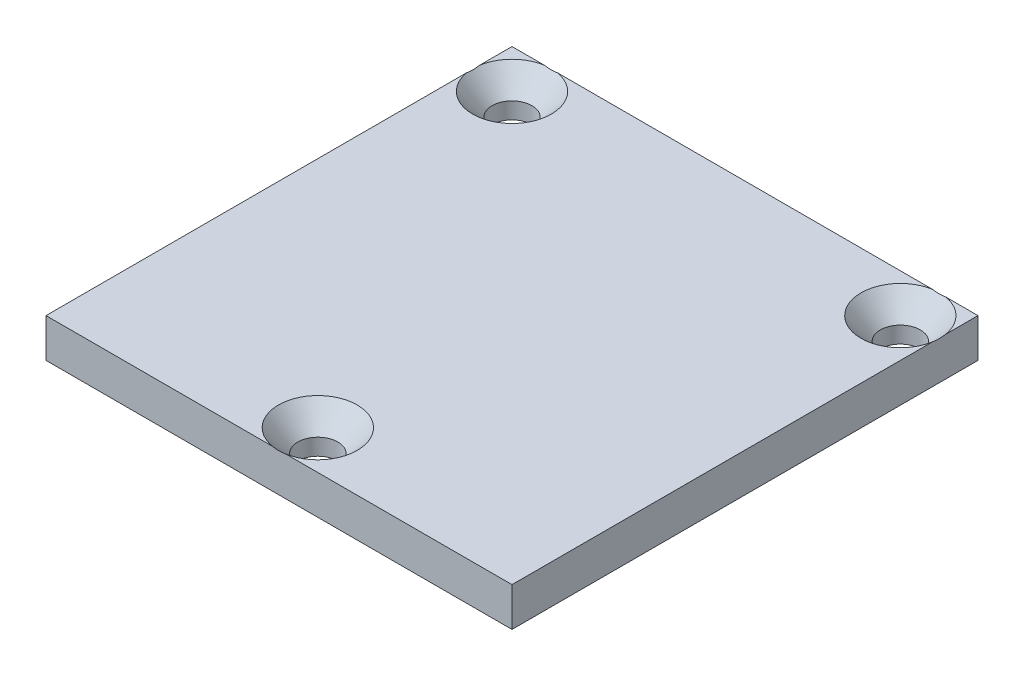
from build123d import *

# Parameters (mm, degrees)
SKETCH1_W            = 76.2
SKETCH1_H            = 76.2
EXTRUDE1_DEPTH       = 6.35
SKETCH16_W           = 1.527820346
SKETCH16_H           = 0.474151141
CUT_EXTRUDE3_DEPTH   = 0.127
LPATTERN2_COUNT      = 3
LPATTERN2_PITCH      = 31.75
LPATTERN2_COUNT_DIR2 = 3
LPATTERN2_PITCH_DIR2 = 31.75


with BuildPart() as part:
    # Sketch1 → Extrude1 (new body)
    with BuildSketch(Plane(origin=(0, 0, 0), x_dir=(1, 0, 0), z_dir=(0, 1, 0))):
        Rectangle(SKETCH1_W, SKETCH1_H)
    extrude(amount=EXTRUDE1_DEPTH)

    # Sketch16 → Cut-Extrude3 (cut)
    with BuildSketch(Plane(origin=(0, 0, -38.1), x_dir=(-1, 0, 0), z_dir=(0, 0, -1))):
        with BuildLine():
            Line((-21.995344635, 1.27), (-21.995344635, 5.379309896))
            Line((-21.995344635, 5.379309896), (-20.456822961, 5.379309896))
            add(Edge.make_bspline(
                [(-20.456822961, 5.379309896), (-20.418670168, 5.379163533), (-20.344223223, 5.378877936), (-20.235515289, 5.371735465), (-20.132560757, 5.361966046), (-20.035137992, 5.349372964), (-19.943668539, 5.331100659), (-19.858237639, 5.308964983), (-19.778400711, 5.283432196), (-19.680812231, 5.244537491), (-19.568352208, 5.184670273), (-19.44789684, 5.095338936), (-19.343095989, 4.988084044), (-19.256860301, 4.865110237), (-19.185811395, 4.733751019), (-19.135438552, 4.596508908), (-19.103232465, 4.456371998), (-19.099578309, 4.36148124), (-19.097754324, 4.314116185)],
                knots=[0, 0, 0, 0, 0.939712594, 1.833646414, 2.682508961, 3.487467313, 4.25240329, 4.978730417, 5.660668875, 6.315918528, 7.564895217, 8.787077865, 9.996481721, 11.241996224, 12.475862915, 13.665015424, 14.834484263, 16, 16, 16, 16], degree=3))
            add(Edge.make_bspline(
                [(-19.097754324, 4.314116185), (-19.099671717, 4.270049426), (-19.103488018, 4.182340752), (-19.133861507, 4.053140541), (-19.181800165, 3.927687941), (-19.249586784, 3.807508077), (-19.33622658, 3.694799613), (-19.443635186, 3.593375963), (-19.57026915, 3.503019762), (-19.665307935, 3.454857251), (-19.714315444, 3.430021868)],
                knots=[0, 0, 0, 0, 0.926741525, 1.844548388, 2.778836836, 3.746021974, 4.738420572, 5.759761325, 6.844803049, 8, 8, 8, 8], degree=3))
            add(Edge.make_bspline(
                [(-19.714315444, 3.430021868), (-19.683999074, 3.420531545), (-19.624644781, 3.401951105), (-19.539316819, 3.367951508), (-19.459219921, 3.3292381), (-19.384179741, 3.285747265), (-19.314703314, 3.237076257), (-19.250986677, 3.183149199), (-19.192588046, 3.124800599), (-19.139611757, 3.06206595), (-19.093077645, 2.995348962), (-19.05134236, 2.926107806), (-19.016879177, 2.853508665), (-18.988630961, 2.777740025), (-18.966593153, 2.69927007), (-18.950767608, 2.617796991), (-18.941747451, 2.533510432), (-18.940392653, 2.476252855), (-18.939703943, 2.447146064)],
                knots=[0, 0, 0, 0, 1.127427615, 2.20731145, 3.257257018, 4.283066884, 5.282973838, 6.264540225, 7.242620376, 8.210460609, 9.17525685, 10.12748095, 11.077310519, 12.023587065, 12.994999128, 13.967387486, 14.966724908, 16, 16, 16, 16], degree=3))
            add(Edge.make_bspline(
                [(-18.939703943, 2.447146064), (-18.941123478, 2.400415518), (-18.943937171, 2.30778989), (-18.966534255, 2.171460543), (-19.00472213, 2.040323201), (-19.057284492, 1.916498196), (-19.119914662, 1.802003749), (-19.191096044, 1.699837698), (-19.269013367, 1.611051323), (-19.355860701, 1.536366113), (-19.451077844, 1.472980225), (-19.557354131, 1.419605162), (-19.673867854, 1.372533471), (-19.802987088, 1.334930867), (-19.944653059, 1.305059407), (-20.100788303, 1.285651871), (-20.2716327, 1.271758677), (-20.390662074, 1.270602609), (-20.452707066, 1.27)],
                knots=[0, 0, 0, 0, 1.028073207, 2.037766189, 3.031549473, 4.027532207, 4.992436545, 5.898794514, 6.762903869, 7.584966804, 8.412380356, 9.273953678, 10.198004568, 11.174406109, 12.229717296, 13.381036288, 14.634844708, 16, 16, 16, 16], degree=3))
            Line((-20.452707066, 1.27), (-21.995344635, 1.27))
        make_face()
        with BuildLine():
            Line((-21.415826573, 3.640755709), (-20.568775314, 3.640755709))
            add(Edge.make_bspline(
                [(-20.568775314, 3.640755709), (-20.541057688, 3.640865371), (-20.487805867, 3.641076055), (-20.410991384, 3.644013623), (-20.340095298, 3.646519789), (-20.275391845, 3.652810073), (-20.216560478, 3.658971126), (-20.163836634, 3.667264865), (-20.116962068, 3.676610026), (-20.088260764, 3.685278367), (-20.074867875, 3.689323274)],
                knots=[0, 0, 0, 0, 1.335841395, 2.566453063, 3.705076039, 4.753984432, 5.69893722, 6.555639608, 7.326018133, 8, 8, 8, 8], degree=3))
            add(Edge.make_bspline(
                [(-20.074867875, 3.689323274), (-20.043399388, 3.700346687), (-19.98273473, 3.721597522), (-19.901438415, 3.769860303), (-19.832197584, 3.827775404), (-19.775197788, 3.896365465), (-19.73139627, 3.975263419), (-19.698918708, 4.062833114), (-19.681136522, 4.160298694), (-19.678595445, 4.22788765), (-19.677272386, 4.263079083)],
                knots=[0, 0, 0, 0, 1.059015028, 2.041559358, 2.989777133, 3.920090524, 4.862499371, 5.848878527, 6.879979022, 8, 8, 8, 8], degree=3))
            add(Edge.make_bspline(
                [(-19.677272386, 4.263079083), (-19.678336215, 4.296900327), (-19.680409494, 4.362814032), (-19.697812823, 4.45853216), (-19.727928642, 4.547580301), (-19.768713706, 4.629938921), (-19.820358435, 4.703208743), (-19.881998221, 4.76620364), (-19.955838332, 4.813825008), (-20.024856719, 4.843531315), (-20.086933288, 4.862115413), (-20.142396523, 4.873110859), (-20.205308373, 4.882798941), (-20.275875865, 4.891035425), (-20.354125692, 4.897427696), (-20.440298956, 4.902505932), (-20.534190527, 4.904662027), (-20.599232437, 4.904989056), (-20.632983281, 4.905158754)],
                knots=[0, 0, 0, 0, 1.216168307, 2.37017178, 3.484610845, 4.588286376, 5.664695412, 6.69777344, 7.738183022, 8.803673002, 9.390844981, 10.0665252, 10.835811589, 11.680682236, 12.621801058, 13.660007223, 14.785756265, 16, 16, 16, 16], degree=3))
            Line((-20.632983281, 4.905158754), (-21.415826573, 4.905158754))
            Line((-21.415826573, 4.905158754), (-21.415826573, 3.640755709))
        make_face(mode=Mode.SUBTRACT)
        with BuildLine():
            Line((-21.415826573, 1.744151142), (-20.443652096, 1.744151142))
            add(Edge.make_bspline(
                [(-20.443652096, 1.744151142), (-20.404961795, 1.744595639), (-20.333877036, 1.745412302), (-20.236646975, 1.747974214), (-20.158055025, 1.754232008), (-20.112161479, 1.760970054), (-20.092154635, 1.763907439)],
                knots=[0, 0, 0, 0, 1.317581857, 2.420761387, 3.311546315, 4, 4, 4, 4], degree=3))
            add(Edge.make_bspline(
                [(-20.092154635, 1.763907439), (-20.06347076, 1.769936499), (-20.007931362, 1.781610318), (-19.929634137, 1.807665063), (-19.85784548, 1.837512163), (-19.793818354, 1.87544451), (-19.734530772, 1.919158942), (-19.68300545, 1.97376036), (-19.635548183, 2.035796815), (-19.594430639, 2.106790482), (-19.561181134, 2.185328392), (-19.535769107, 2.27019708), (-19.52223281, 2.361098978), (-19.52023977, 2.423508068), (-19.519222005, 2.455377855)],
                knots=[0, 0, 0, 0, 1.067651492, 2.067249321, 3.003744366, 3.895862395, 4.774133402, 5.679610569, 6.621910665, 7.616993802, 8.661192143, 9.724711987, 10.838102842, 12, 12, 12, 12], degree=3))
            add(Edge.make_bspline(
                [(-19.519222005, 2.455377855), (-19.520355906, 2.492794894), (-19.522567127, 2.565761941), (-19.543585548, 2.67120302), (-19.578304539, 2.769000932), (-19.627178761, 2.857801275), (-19.687125547, 2.937669537), (-19.759655104, 3.00541961), (-19.844225101, 3.059182643), (-19.941095458, 3.101376219), (-20.054317501, 3.131396222), (-20.187017066, 3.151762975), (-20.341316723, 3.164905153), (-20.451578993, 3.166013834), (-20.5103296, 3.166604567)],
                knots=[0, 0, 0, 0, 0.96167883, 1.875371887, 2.752872588, 3.621584364, 4.472914353, 5.312011319, 6.159851575, 7.038572308, 8.019870099, 9.164119506, 10.488969081, 12, 12, 12, 12], degree=3))
            Line((-20.5103296, 3.166604567), (-21.415826573, 3.166604567))
            Line((-21.415826573, 3.166604567), (-21.415826573, 1.744151142))
        make_face(mode=Mode.SUBTRACT)
        Polygon((-18.764366802, 1.27), (-17.132825894, 5.379309896), (-16.479221716, 5.379309896), (-14.847680808, 1.27), (-15.46259557, 1.27), (-15.930161279, 2.534403045), (-17.681886331, 2.534403045), (-18.14945204, 1.27), align=None)
        with BuildLine():
            Line((-17.507372369, 3.008554187), (-16.104675241, 3.008554187))
            Line((-16.104675241, 3.008554187), (-16.503917088, 4.088565121))
            add(Edge.make_bspline(
                [(-16.503917088, 4.088565121), (-16.519222595, 4.130295272), (-16.549147751, 4.211885595), (-16.593775174, 4.330429448), (-16.634546069, 4.443003557), (-16.674525279, 4.547993769), (-16.710615227, 4.646925173), (-16.743880256, 4.739129533), (-16.77677909, 4.823965984), (-16.796522143, 4.878779072), (-16.806023805, 4.905158754)],
                knots=[0, 0, 0, 0, 1.225184869, 2.395467751, 3.491410812, 4.525364584, 5.492066482, 6.394148129, 7.227157926, 8, 8, 8, 8], degree=3))
            add(Edge.make_bspline(
                [(-16.806023805, 4.905158754), (-16.821741388, 4.840108782), (-16.853241363, 4.709740617), (-16.91919464, 4.518733767), (-16.994642899, 4.32947376), (-17.055915876, 4.207515903), (-17.086727866, 4.146187655)],
                knots=[0, 0, 0, 0, 0.9891762, 1.982431084, 2.985436691, 4, 4, 4, 4], degree=3))
            Line((-17.086727866, 4.146187655), (-17.507372369, 3.008554187))
        make_face(mode=Mode.SUBTRACT)
        Polygon((-14.408926366, 1.27), (-14.408926366, 5.379309896), (-13.829408303, 5.379309896), (-13.829408303, 1.744151142), (-11.880120276, 1.744151142), (-11.880120276, 1.27), align=None)
        with Locations((-10.800109342, 2.718795156)):
            Rectangle(SKETCH16_W, SKETCH16_H)
        Polygon((-8.350328442, 1.27), (-8.350328442, 4.905158754), (-9.667414947, 4.905158754), (-9.667414947, 5.379309896), (-6.453723875, 5.379309896), (-6.453723875, 4.905158754), (-7.77081038, 4.905158754), (-7.77081038, 1.27), align=None)
        Polygon((-5.821522352, 1.27), (-5.821522352, 5.379309896), (-2.923932041, 5.379309896), (-2.923932041, 4.905158754), (-5.24200429, 4.905158754), (-5.24200429, 3.640755709), (-3.081982422, 3.640755709), (-3.081982422, 3.166604567), (-5.24200429, 3.166604567), (-5.24200429, 1.744151142), (-2.818565121, 1.744151142), (-2.818565121, 1.27), align=None)
        with BuildLine():
            Line((0.763910173, 2.720441514), (1.343428235, 2.585440147))
            add(Edge.make_bspline(
                [(1.343428235, 2.585440147), (1.32890969, 2.531123529), (1.300509614, 2.424873482), (1.244359213, 2.272817905), (1.181337275, 2.130120231), (1.109914601, 1.997156352), (1.029309477, 1.874690728), (0.941657612, 1.761149439), (0.843487242, 1.658913554), (0.738400352, 1.565623521), (0.625578728, 1.483341962), (0.50638261, 1.412290325), (0.381388169, 1.351839805), (0.250090215, 1.30212901), (0.112403627, 1.264717374), (-0.030962645, 1.237449582), (-0.180426648, 1.22065421), (-0.282306437, 1.21844305), (-0.334210701, 1.21731654)],
                knots=[0, 0, 0, 0, 1.145254194, 2.240259345, 3.299159039, 4.322497661, 5.312016644, 6.284080175, 7.241264552, 8.196044782, 9.144516039, 10.082428046, 11.020306713, 11.970622414, 12.939253955, 13.924100776, 14.94240044, 16, 16, 16, 16], degree=3))
            add(Edge.make_bspline(
                [(-0.334210701, 1.21731654), (-0.38746548, 1.218090236), (-0.491654201, 1.219603911), (-0.64428467, 1.231915742), (-0.789451234, 1.253268696), (-0.926882797, 1.28293557), (-1.057041938, 1.319616815), (-1.179388922, 1.365765072), (-1.293709454, 1.421047363), (-1.400957119, 1.483917616), (-1.5006764, 1.555341055), (-1.595134949, 1.633390154), (-1.682039625, 1.72021352), (-1.763563375, 1.813761172), (-1.837930581, 1.915267134), (-1.907877229, 2.023352405), (-1.969989263, 2.139921443), (-2.026568509, 2.262813054), (-2.076229322, 2.390837427), (-2.120161771, 2.521465727), (-2.15607895, 2.654958245), (-2.187001323, 2.790191665), (-2.209464929, 2.928303884), (-2.227300336, 3.068258635), (-2.237106602, 3.210913965), (-2.238397003, 3.306805835), (-2.239047059, 3.355112573)],
                knots=[0, 0, 0, 0, 1.180702053, 2.309949215, 3.392367133, 4.431746864, 5.425408375, 6.388154007, 7.326956194, 8.237882283, 9.141054626, 10.043899035, 10.951650021, 11.86168169, 12.792564695, 13.739356664, 14.713891418, 15.718426911, 16.737522708, 17.757217648, 18.772674716, 19.801476837, 20.831699174, 21.873853055, 22.928926693, 24, 24, 24, 24], degree=3))
            add(Edge.make_bspline(
                [(-2.239047059, 3.355112573), (-2.238117342, 3.407261645), (-2.236280456, 3.510295039), (-2.225911268, 3.662323803), (-2.206866827, 3.809050158), (-2.180419637, 3.950570618), (-2.146953362, 4.086999795), (-2.105642997, 4.218404156), (-2.057011117, 4.34461557), (-2.001205983, 4.465773212), (-1.937856835, 4.580524641), (-1.868854388, 4.689032987), (-1.792552667, 4.789516591), (-1.711213906, 4.88389522), (-1.622806613, 4.970597363), (-1.527600747, 5.049819422), (-1.426417702, 5.122284002), (-1.319272247, 5.18731837), (-1.207564899, 5.244382626), (-1.092954872, 5.295210256), (-0.974986311, 5.336870408), (-0.854594506, 5.371509149), (-0.731520263, 5.399084805), (-0.605476007, 5.417524733), (-0.476578205, 5.429541618), (-0.389665239, 5.431170194), (-0.345735208, 5.431993356)],
                knots=[0, 0, 0, 0, 1.185634383, 2.342514083, 3.462112933, 4.547331452, 5.613960142, 6.653690668, 7.676612054, 8.686959706, 9.683658101, 10.654407272, 11.607580201, 12.5494388, 13.484601218, 14.419076806, 15.362504069, 16.311442244, 17.265594461, 18.212500624, 19.159571152, 20.107257795, 21.059246075, 22.024387127, 23.001429356, 24, 24, 24, 24], degree=3))
            add(Edge.make_bspline(
                [(-0.345735208, 5.431993356), (-0.29658342, 5.431066869), (-0.199970716, 5.429245767), (-0.058208785, 5.414266847), (0.077562132, 5.389178796), (0.207930354, 5.356265645), (0.331540467, 5.311200691), (0.449734473, 5.25762364), (0.561336575, 5.193257302), (0.667215134, 5.119870583), (0.765646608, 5.037328138), (0.858008441, 4.947601885), (0.940534603, 4.848449322), (1.016493632, 4.742270118), (1.083495604, 4.627591929), (1.144005452, 4.505414625), (1.196042161, 4.37482996), (1.223884392, 4.283874128), (1.238061315, 4.237560532)],
                knots=[0, 0, 0, 0, 1.098391872, 2.158997981, 3.181470371, 4.182549255, 5.160268219, 6.118029851, 7.079534476, 8.035645336, 8.993622929, 9.94770573, 10.909620999, 11.872786677, 12.862530088, 13.874594564, 14.917769567, 16, 16, 16, 16], degree=3))
            Line((1.238061315, 4.237560532), (0.658543253, 4.113260493))
            add(Edge.make_bspline(
                [(0.658543253, 4.113260493), (0.647162422, 4.1488038), (0.624886616, 4.21837305), (0.585333744, 4.317521594), (0.54261796, 4.409563838), (0.49572174, 4.493874117), (0.44454345, 4.570472628), (0.390261591, 4.640290312), (0.331575622, 4.70202401), (0.269679266, 4.757097149), (0.202974177, 4.804014192), (0.133024212, 4.845590414), (0.058354477, 4.879988398), (-0.019960849, 4.909081986), (-0.102653772, 4.931225341), (-0.189387553, 4.946804065), (-0.280238401, 4.955820267), (-0.342148151, 4.957159288), (-0.373723296, 4.957842214)],
                knots=[0, 0, 0, 0, 1.235697765, 2.418642872, 3.532555292, 4.594392283, 5.610119701, 6.580908344, 7.519430642, 8.427315627, 9.319973334, 10.216139639, 11.118687699, 12.038725643, 12.980015607, 13.949697744, 14.954307006, 16, 16, 16, 16], degree=3))
            add(Edge.make_bspline(
                [(-0.373723296, 4.957842214), (-0.409974451, 4.957316246), (-0.481269776, 4.956281822), (-0.586011184, 4.944960162), (-0.686599367, 4.928284462), (-0.782284644, 4.903277816), (-0.873590612, 4.872101032), (-0.959975445, 4.833280419), (-1.042173971, 4.787778107), (-1.119268812, 4.735320849), (-1.190612056, 4.676348796), (-1.258139753, 4.614006109), (-1.318609823, 4.545385267), (-1.374328171, 4.472748971), (-1.423672282, 4.394813686), (-1.468090248, 4.312640984), (-1.507298938, 4.225557396), (-1.550039072, 4.102993842), (-1.593618368, 3.945134818), (-1.63142346, 3.751966538), (-1.655504413, 3.555754905), (-1.658184632, 3.423779385), (-1.659528996, 3.357582111)],
                knots=[0, 0, 0, 0, 0.935256702, 1.839373932, 2.716087708, 3.564631604, 4.388828665, 5.203538865, 6.005592122, 6.810952829, 7.606223804, 8.392839071, 9.180346482, 9.963639178, 10.753404291, 11.558266631, 12.372976832, 13.215232055, 14.905983541, 16.594894834, 18.292041732, 20, 20, 20, 20], degree=3))
            add(Edge.make_bspline(
                [(-1.659528996, 3.357582111), (-1.658012744, 3.274350116), (-1.655071077, 3.112872509), (-1.626044057, 2.878864784), (-1.581788384, 2.660598565), (-1.528378163, 2.490307425), (-1.474802345, 2.364697473), (-1.431472916, 2.276731013), (-1.3820141, 2.195331117), (-1.32765612, 2.120035508), (-1.267698787, 2.051063819), (-1.202977429, 1.988049668), (-1.133477588, 1.930386711), (-1.058375757, 1.880774256), (-0.980562698, 1.836722721), (-0.90102035, 1.797551255), (-0.819698632, 1.764421763), (-0.736269445, 1.738686101), (-0.651904359, 1.716446911), (-0.565674179, 1.701919228), (-0.477603494, 1.693720262), (-0.418466207, 1.692224562), (-0.388540519, 1.691467682)],
                knots=[0, 0, 0, 0, 2.10686522, 4.087509323, 5.961373225, 7.741398778, 8.594514555, 9.418024779, 10.222433421, 11.003575649, 11.767087398, 12.533660211, 13.289033706, 14.050297079, 14.809623433, 15.552362432, 16.294320901, 17.0305302, 17.761969017, 18.502233515, 19.242073914, 20, 20, 20, 20], degree=3))
            add(Edge.make_bspline(
                [(-0.388540519, 1.691467682), (-0.352828308, 1.692216642), (-0.282284064, 1.693696103), (-0.178857244, 1.70664591), (-0.079155216, 1.725729144), (0.015614145, 1.755176502), (0.106725593, 1.791231342), (0.193432627, 1.835693264), (0.275462566, 1.88916798), (0.353780262, 1.949883497), (0.426941469, 2.01896738), (0.493989781, 2.095863056), (0.554139693, 2.18092108), (0.609913797, 2.272776396), (0.656774296, 2.374173061), (0.700178182, 2.482088887), (0.736345436, 2.598297566), (0.754589937, 2.679141993), (0.763910173, 2.720441514)],
                knots=[0, 0, 0, 0, 1.013374089, 2.001772144, 2.95501459, 3.891367103, 4.814208647, 5.733921849, 6.652182523, 7.590185968, 8.54346024, 9.504121027, 10.481158517, 11.497760682, 12.549996529, 13.647863555, 14.798406869, 16, 16, 16, 16], degree=3))
        make_face()
        with BuildLine():
            Line((5.031270449, 2.692453425), (5.610788512, 2.692453425))
            add(Edge.make_bspline(
                [(5.610788512, 2.692453425), (5.617162874, 2.640420672), (5.629408368, 2.540462952), (5.663647991, 2.398787931), (5.707716595, 2.271407547), (5.762624861, 2.156631237), (5.834854593, 2.055835164), (5.921878995, 1.964918645), (6.027565395, 1.886190445), (6.146861249, 1.816127505), (6.279723537, 1.761117016), (6.421565879, 1.720336835), (6.571711811, 1.696174253), (6.674522506, 1.69305859), (6.727019325, 1.691467682)],
                knots=[0, 0, 0, 0, 1.125557648, 2.162256852, 3.1243583, 4.018160113, 4.88511607, 5.777380551, 6.711250965, 7.707237736, 8.743031335, 9.791730543, 10.872421559, 12, 12, 12, 12], degree=3))
            add(Edge.make_bspline(
                [(6.727019325, 1.691467682), (6.773474488, 1.692327517), (6.864053062, 1.69400403), (6.995085094, 1.714143104), (7.118386616, 1.742709839), (7.23166286, 1.785921499), (7.334495959, 1.838394002), (7.423794986, 1.901860726), (7.500033745, 1.973433756), (7.559734219, 2.054998286), (7.606633719, 2.140464274), (7.641039351, 2.228314495), (7.661534081, 2.318061341), (7.664145643, 2.378447645), (7.66544346, 2.408456648)],
                knots=[0, 0, 0, 0, 1.267006637, 2.470417599, 3.611360613, 4.716023143, 5.771382139, 6.754486395, 7.697536124, 8.612899418, 9.501261124, 10.352596716, 11.181322154, 12, 12, 12, 12], degree=3))
            add(Edge.make_bspline(
                [(7.66544346, 2.408456648), (7.664056069, 2.438161677), (7.661344417, 2.496220113), (7.643673331, 2.580745944), (7.610086933, 2.658111632), (7.566504723, 2.731474882), (7.505874428, 2.79854968), (7.429274892, 2.860353123), (7.335018436, 2.916384723), (7.264670171, 2.947070893), (7.227512197, 2.963279338)],
                knots=[0, 0, 0, 0, 0.942140154, 1.841411588, 2.718743672, 3.605002079, 4.535543111, 5.568170452, 6.715506882, 8, 8, 8, 8], degree=3))
            add(Edge.make_bspline(
                [(7.227512197, 2.963279338), (7.2130349, 2.969220343), (7.180328057, 2.982642152), (7.124270063, 3.000410316), (7.057750154, 3.023386365), (6.979170243, 3.047047957), (6.888951001, 3.072078611), (6.787242636, 3.100409517), (6.67410198, 3.130537884), (6.552737898, 3.16260625), (6.430197159, 3.19521486), (6.313123798, 3.227854008), (6.20541074, 3.260986923), (6.106175671, 3.292889346), (6.015930191, 3.324923389), (5.934418163, 3.356212027), (5.861537962, 3.386120456), (5.81702551, 3.408111666), (5.796003801, 3.418497361)],
                knots=[0, 0, 0, 0, 0.499201778, 1.127787504, 1.87543728, 2.745208432, 3.745951656, 4.863402235, 6.114490242, 7.482339553, 8.869366102, 10.161191451, 11.360587006, 12.46547846, 13.487450326, 14.41601931, 15.251940103, 16, 16, 16, 16], degree=3))
            add(Edge.make_bspline(
                [(5.796003801, 3.418497361), (5.747638713, 3.444625575), (5.654281506, 3.495059828), (5.528633046, 3.585236412), (5.422761462, 3.685304023), (5.337113407, 3.795117558), (5.269994377, 3.912819807), (5.224709462, 4.038610865), (5.193693033, 4.170207389), (5.190794467, 4.260700631), (5.18932083, 4.306707573)],
                knots=[0, 0, 0, 0, 1.158441928, 2.236094408, 3.251151369, 4.220012324, 5.163146324, 6.095083285, 7.031536583, 8, 8, 8, 8], degree=3))
            add(Edge.make_bspline(
                [(5.18932083, 4.306707573), (5.191276639, 4.357652491), (5.195166729, 4.458981563), (5.22967396, 4.607675659), (5.284713653, 4.750758931), (5.347365539, 4.864354839), (5.408464972, 4.950255556), (5.459116867, 5.012119683), (5.515932874, 5.069304751), (5.577163257, 5.122609025), (5.643902572, 5.171236078), (5.714495009, 5.217184422), (5.791495621, 5.256678125), (5.899692931, 5.306944695), (6.044434863, 5.357140566), (6.22664685, 5.400879901), (6.418418984, 5.426637086), (6.549135375, 5.430182678), (6.615890151, 5.431993356)],
                knots=[0, 0, 0, 0, 1.199927478, 2.386647047, 3.578628709, 4.806592355, 5.433127754, 6.062729195, 6.689531802, 7.331674828, 7.974827539, 8.635320743, 9.315455226, 10.01318112, 11.447700238, 12.918145351, 14.426146008, 16, 16, 16, 16], degree=3))
            add(Edge.make_bspline(
                [(6.615890151, 5.431993356), (6.688957686, 5.430319125), (6.831234257, 5.427059075), (7.037966136, 5.39993605), (7.230790384, 5.353358679), (7.382009775, 5.301219985), (7.493804503, 5.248436632), (7.57322659, 5.207250317), (7.646945992, 5.159631435), (7.715626333, 5.108100355), (7.77990556, 5.052680611), (7.838131552, 4.99205395), (7.892832644, 4.928288845), (7.95711405, 4.836742132), (8.026423033, 4.715580576), (8.086350083, 4.558610968), (8.127520666, 4.392942434), (8.135529291, 4.278411536), (8.139594601, 4.220273771)],
                knots=[0, 0, 0, 0, 1.607600973, 3.130308851, 4.577334065, 5.967726088, 6.640410691, 7.296826776, 7.935019992, 8.569057421, 9.185393759, 9.8003086, 10.417295362, 11.032210203, 12.259799365, 13.477607022, 14.719591916, 16, 16, 16, 16], degree=3))
            Line((8.139594601, 4.220273771), (7.560076539, 4.220273771))
            add(Edge.make_bspline(
                [(7.560076539, 4.220273771), (7.556394367, 4.249698994), (7.549189447, 4.307275433), (7.531314997, 4.390625991), (7.506258614, 4.468038239), (7.476909912, 4.540234098), (7.44133314, 4.606462652), (7.399860918, 4.66735984), (7.351988204, 4.722208188), (7.298946811, 4.772457001), (7.239122701, 4.816209691), (7.172823267, 4.854188369), (7.099936596, 4.886271655), (7.020526898, 4.912548913), (6.934578454, 4.932923271), (6.841895772, 4.947911038), (6.742514676, 4.955586944), (6.674072463, 4.957077216), (6.638939165, 4.957842214)],
                knots=[0, 0, 0, 0, 1.074487479, 2.102453544, 3.083708351, 4.020042547, 4.923259678, 5.803182661, 6.684453325, 7.556870173, 8.445961597, 9.363679789, 10.320905216, 11.327237703, 12.390948353, 13.519046902, 14.726457512, 16, 16, 16, 16], degree=3))
            add(Edge.make_bspline(
                [(6.638939165, 4.957842214), (6.602419739, 4.957566948), (6.531727114, 4.9570341), (6.429532907, 4.947320955), (6.334812086, 4.933994174), (6.247727345, 4.914336039), (6.168563963, 4.888603475), (6.09614704, 4.858888268), (6.032503242, 4.82123134), (5.976148921, 4.77928642), (5.927536182, 4.732876683), (5.885639202, 4.683972041), (5.84858456, 4.634009347), (5.819792285, 4.580257608), (5.796351046, 4.524752484), (5.781228871, 4.466450661), (5.770522017, 4.40643057), (5.769407687, 4.365477659), (5.768838892, 4.34457381)],
                knots=[0, 0, 0, 0, 1.464176581, 2.834285765, 4.113735764, 5.29917439, 6.409476712, 7.449999357, 8.431575861, 9.367089851, 10.262376129, 11.120706676, 11.948504824, 12.751342953, 13.560717798, 14.359016663, 15.162382702, 16, 16, 16, 16], degree=3))
            add(Edge.make_bspline(
                [(5.768838892, 4.34457381), (5.770336503, 4.309219114), (5.773243228, 4.240598909), (5.802925141, 4.143110282), (5.84857613, 4.054243082), (5.893549627, 4.005890893), (5.916187945, 3.981551842)],
                knots=[0, 0, 0, 0, 1.050964922, 2.039826012, 3.013306874, 4, 4, 4, 4], degree=3))
            add(Edge.make_bspline(
                [(5.916187945, 3.981551842), (5.930458899, 3.96938835), (5.962018233, 3.942489537), (6.020739238, 3.906892107), (6.093544576, 3.870925441), (6.180920719, 3.835171792), (6.282717335, 3.799197114), (6.398770222, 3.762156759), (6.529521414, 3.725368761), (6.67098627, 3.689917439), (6.813898762, 3.654323599), (6.949713675, 3.618865418), (7.074414754, 3.58526082), (7.187804153, 3.552485039), (7.289999232, 3.520630754), (7.380644827, 3.489030575), (7.460474294, 3.459966426), (7.509379274, 3.439517425), (7.532088451, 3.430021868)],
                knots=[0, 0, 0, 0, 0.523891492, 1.158553688, 1.913783773, 2.794766643, 3.797521443, 4.933638669, 6.202080764, 7.596537849, 9.013317056, 10.322179469, 11.523240428, 12.626146501, 13.623953177, 14.517289671, 15.311498917, 16, 16, 16, 16], degree=3))
            add(Edge.make_bspline(
                [(7.532088451, 3.430021868), (7.561634243, 3.416399361), (7.619627681, 3.389660662), (7.701783152, 3.344008355), (7.77844312, 3.296600892), (7.848988223, 3.246161904), (7.913190354, 3.192585294), (7.97176737, 3.136484932), (8.025073053, 3.07817611), (8.070956526, 3.015792608), (8.112155177, 2.951856247), (8.148206739, 2.885473435), (8.177234765, 2.816253787), (8.202694155, 2.745031681), (8.221006758, 2.671014921), (8.235367533, 2.594951125), (8.243743933, 2.516482772), (8.24455215, 2.463354726), (8.244961522, 2.436444736)],
                knots=[0, 0, 0, 0, 1.198900896, 2.353241543, 3.461831299, 4.520043694, 5.547003373, 6.541368882, 7.508191797, 8.454912692, 9.392021408, 10.310662301, 11.235020644, 12.156274873, 13.095836685, 14.042125239, 15.00831306, 16, 16, 16, 16], degree=3))
            add(Edge.make_bspline(
                [(8.244961522, 2.436444736), (8.242816951, 2.38273971), (8.238559265, 2.276117385), (8.201899051, 2.118951145), (8.144307793, 1.966657936), (8.076767779, 1.845804886), (8.012922051, 1.753490719), (7.959288627, 1.687139515), (7.899812245, 1.625787715), (7.835957151, 1.567513285), (7.767227571, 1.513505214), (7.693044071, 1.46374511), (7.614189625, 1.417714976), (7.501587459, 1.361624561), (7.352033075, 1.302948662), (7.161530814, 1.25408536), (6.960764504, 1.222386528), (6.822905963, 1.219029891), (6.752537876, 1.21731654)],
                knots=[0, 0, 0, 0, 1.197055466, 2.376552968, 3.581957237, 4.820753935, 5.454298064, 6.085440993, 6.72202542, 7.359198513, 8.013298489, 8.67051481, 9.351020706, 10.049282741, 11.476266879, 12.925760103, 14.430794493, 16, 16, 16, 16], degree=3))
            add(Edge.make_bspline(
                [(6.752537876, 1.21731654), (6.707796385, 1.217685767), (6.620154197, 1.21840903), (6.49137379, 1.227167977), (6.367961172, 1.239838224), (6.250037455, 1.258710699), (6.137972437, 1.28347036), (6.031363856, 1.313201928), (5.929959018, 1.347443959), (5.834112235, 1.387711993), (5.744073708, 1.43449905), (5.658224453, 1.484970447), (5.577967733, 1.54218214), (5.503134598, 1.605235136), (5.431828934, 1.672307889), (5.367006151, 1.746139596), (5.306462438, 1.824571151), (5.251581202, 1.90832039), (5.202553173, 1.996291596), (5.158463007, 2.087007387), (5.121316425, 2.181125835), (5.091379814, 2.278171267), (5.066021989, 2.377494255), (5.048436924, 2.479923476), (5.035507791, 2.585137338), (5.03269124, 2.656470103), (5.031270449, 2.692453425)],
                knots=[0, 0, 0, 0, 1.259822038, 2.467811403, 3.633536148, 4.752793854, 5.829021491, 6.863980041, 7.868367876, 8.841470325, 9.788447787, 10.724101269, 11.643985084, 12.560193707, 13.478453146, 14.398077254, 15.323914234, 16.266973849, 17.21495974, 18.158525798, 19.105629373, 20.061269543, 21.017128399, 21.990322895, 22.986232211, 24, 24, 24, 24], degree=3))
        make_face()
        with BuildLine():
            Line((9.035213425, 1.27), (9.035213425, 5.379309896))
            Line((9.035213425, 5.379309896), (10.544923831, 5.379309896))
            add(Edge.make_bspline(
                [(10.544923831, 5.379309896), (10.607500111, 5.378953394), (10.725018657, 5.378283881), (10.889131797, 5.370443025), (11.030058416, 5.360742589), (11.11517866, 5.346931692), (11.15407634, 5.34062048)],
                knots=[0, 0, 0, 0, 1.22865052, 2.30741144, 3.226532197, 4, 4, 4, 4], degree=3))
            add(Edge.make_bspline(
                [(11.15407634, 5.34062048), (11.201522119, 5.331489433), (11.293485265, 5.31379092), (11.423690826, 5.271123645), (11.542315634, 5.218027477), (11.649174302, 5.151875131), (11.746042083, 5.074162306), (11.831538501, 4.981044098), (11.907324622, 4.874599674), (11.971765974, 4.75491232), (12.025403527, 4.626128778), (12.062971478, 4.488929745), (12.087033818, 4.345698867), (12.089566539, 4.24781158), (12.090854117, 4.198047937)],
                knots=[0, 0, 0, 0, 1.070909925, 2.075721949, 3.031861647, 3.947440733, 4.85625699, 5.777986723, 6.742441087, 7.747548058, 8.78749499, 9.830146138, 10.896896232, 12, 12, 12, 12], degree=3))
            add(Edge.make_bspline(
                [(12.090854117, 4.198047937), (12.089946708, 4.155470182), (12.088161331, 4.071696116), (12.072830585, 3.948619924), (12.048650684, 3.830215623), (12.012583082, 3.717293472), (11.96848947, 3.6085333), (11.912921331, 3.505769374), (11.848033421, 3.407606246), (11.773586853, 3.314311026), (11.685942565, 3.227776888), (11.580495712, 3.154369684), (11.459279321, 3.092728268), (11.322265118, 3.042922671), (11.16978571, 3.003733691), (11.001341491, 2.975020483), (10.81660433, 2.959168403), (10.68818669, 2.956998101), (10.621479484, 2.955870726)],
                knots=[0, 0, 0, 0, 0.928769099, 1.82740408, 2.702266355, 3.562020322, 4.410419678, 5.259600434, 6.10654066, 6.975254961, 7.860221694, 8.783881459, 9.766664779, 10.81996744, 11.958551584, 13.197863772, 14.544415867, 16, 16, 16, 16], degree=3))
            Line((10.621479484, 2.955870726), (9.614731487, 2.955870726))
            Line((9.614731487, 2.955870726), (9.614731487, 1.27))
            Line((9.614731487, 1.27), (9.035213425, 1.27))
        make_face()
        with BuildLine():
            Line((9.614731487, 3.430021868), (10.605839082, 3.430021868))
            add(Edge.make_bspline(
                [(10.605839082, 3.430021868), (10.645368348, 3.430682813), (10.721517814, 3.431956061), (10.831550321, 3.440841477), (10.93253301, 3.456221723), (11.024746, 3.477672663), (11.108306708, 3.504335566), (11.183065625, 3.5380568), (11.248637244, 3.578507336), (11.305456059, 3.625274979), (11.3542286, 3.677666149), (11.396488847, 3.734822025), (11.432395437, 3.797151049), (11.46054196, 3.864914), (11.484385946, 3.936792757), (11.499268898, 4.014276653), (11.509616968, 4.096242057), (11.510754991, 4.152738058), (11.511336054, 4.181584355)],
                knots=[0, 0, 0, 0, 1.403696362, 2.704090955, 3.91683431, 5.027708188, 6.063065288, 7.026749679, 7.932587242, 8.790956304, 9.632005367, 10.468072405, 11.310475089, 12.179234342, 13.069796908, 13.994719932, 14.976123913, 16, 16, 16, 16], degree=3))
            add(Edge.make_bspline(
                [(11.511336054, 4.181584355), (11.510108479, 4.223416087), (11.507729865, 4.304471377), (11.483764745, 4.421107444), (11.446192499, 4.528881237), (11.3924001, 4.62575226), (11.327295651, 4.710733949), (11.25076675, 4.780262958), (11.165266936, 4.835848839), (11.101428708, 4.857858137), (11.069288896, 4.868938875)],
                knots=[0, 0, 0, 0, 1.143156811, 2.215038775, 3.243253804, 4.254666983, 5.233799895, 6.158487526, 7.072877374, 8, 8, 8, 8], degree=3))
            add(Edge.make_bspline(
                [(11.069288896, 4.868938875), (11.057518267, 4.871817054), (11.03193988, 4.878071535), (10.989569483, 4.885170465), (10.940464425, 4.891892521), (10.884385344, 4.896352292), (10.821843666, 4.900781412), (10.752648195, 4.902823126), (10.676641304, 4.904586585), (10.623676035, 4.904962204), (10.595960933, 4.905158754)],
                knots=[0, 0, 0, 0, 0.611063981, 1.327884044, 2.165719042, 3.110592661, 4.16481496, 5.328235826, 6.601947678, 8, 8, 8, 8], degree=3))
            Line((10.595960933, 4.905158754), (9.614731487, 4.905158754))
            Line((9.614731487, 4.905158754), (9.614731487, 3.430021868))
        make_face(mode=Mode.SUBTRACT)
        with Locations((13.276231971, 2.718795156)):
            Rectangle(SKETCH16_W, SKETCH16_H)
        with BuildLine():
            Line((14.514293286, 2.376352664), (15.041127888, 2.429036124))
            add(Edge.make_bspline(
                [(15.041127888, 2.429036124), (15.048151224, 2.397380781), (15.061740859, 2.336130041), (15.087888976, 2.248381991), (15.115507129, 2.166932181), (15.149745192, 2.093602444), (15.183154101, 2.0253939), (15.222414628, 1.965124861), (15.264365262, 1.911222828), (15.309781532, 1.863887951), (15.359186777, 1.823126841), (15.411922317, 1.787458672), (15.469103459, 1.757670947), (15.530292411, 1.73408633), (15.594973815, 1.714994381), (15.663499181, 1.700975509), (15.736230862, 1.692624293), (15.786082525, 1.69185951), (15.811623493, 1.691467682)],
                knots=[0, 0, 0, 0, 1.321063709, 2.556160278, 3.730472002, 4.821700466, 5.852032229, 6.822994757, 7.746964065, 8.632786469, 9.490489437, 10.352773447, 11.223141997, 12.11199479, 13.021433979, 13.96892724, 14.959401504, 16, 16, 16, 16], degree=3))
            add(Edge.make_bspline(
                [(15.811623493, 1.691467682), (15.841582143, 1.691894819), (15.900091436, 1.69272902), (15.985349127, 1.705245219), (16.066486855, 1.722431152), (16.142346999, 1.749379677), (16.21398587, 1.782315759), (16.280995338, 1.823017768), (16.343834079, 1.870812112), (16.401262644, 1.926023893), (16.452620867, 1.986758612), (16.49836258, 2.050909975), (16.536184831, 2.119025368), (16.568063294, 2.190145365), (16.591593768, 2.265419231), (16.608819975, 2.34390834), (16.62007739, 2.425967651), (16.621106482, 2.481956273), (16.621631694, 2.510530852)],
                knots=[0, 0, 0, 0, 1.111377895, 2.170522867, 3.193923215, 4.186422864, 5.152846954, 6.117443035, 7.091571248, 8.078879332, 9.069127402, 10.041602243, 10.999610288, 11.957618333, 12.930786866, 13.922135183, 14.939532534, 16, 16, 16, 16], degree=3))
            add(Edge.make_bspline(
                [(16.621631694, 2.510530852), (16.621014416, 2.537723928), (16.61980676, 2.590925013), (16.609878856, 2.669012791), (16.592554881, 2.743139155), (16.568539711, 2.8137331), (16.537853252, 2.88069099), (16.500969033, 2.944566503), (16.45585661, 3.003959805), (16.405078599, 3.059508831), (16.349694603, 3.110685423), (16.289085327, 3.154217701), (16.225301589, 3.191787476), (16.157583234, 3.2221236), (16.086211431, 3.246201555), (16.011254219, 3.263506854), (15.93235122, 3.273439067), (15.878603478, 3.274646933), (15.851136089, 3.275264204)],
                knots=[0, 0, 0, 0, 1.072815875, 2.098878726, 3.09954706, 4.07199174, 5.036203424, 6.001873089, 6.97636515, 7.972747947, 8.969130744, 9.945905975, 10.911575641, 11.885646534, 12.868345115, 13.879560892, 14.916365174, 16, 16, 16, 16], degree=3))
            add(Edge.make_bspline(
                [(15.851136089, 3.275264204), (15.826952721, 3.27462351), (15.775629977, 3.273263809), (15.694625511, 3.261258163), (15.604899345, 3.244447443), (15.542896004, 3.227950215), (15.510339955, 3.219288028)],
                knots=[0, 0, 0, 0, 0.837610211, 1.777604146, 2.833088267, 4, 4, 4, 4], degree=3))
            Line((15.510339955, 3.219288028), (15.564669774, 3.693439169))
            add(Edge.make_bspline(
                [(15.564669774, 3.693439169), (15.578924647, 3.691881501), (15.604108102, 3.689129637), (15.629418555, 3.688116553), (15.640402248, 3.687676916)],
                knots=[0, 0, 0, 0, 1.132082448, 2, 2, 2, 2], degree=3))
            add(Edge.make_bspline(
                [(15.640402248, 3.687676916), (15.688853585, 3.689526769), (15.783899878, 3.6931556), (15.922458949, 3.723308145), (16.05377231, 3.770782354), (16.155220364, 3.827425973), (16.230450813, 3.880702373), (16.277889622, 3.928738606), (16.320658155, 3.979714752), (16.352566976, 4.038186238), (16.380134229, 4.100313604), (16.397205188, 4.168544212), (16.409654728, 4.241219553), (16.410476038, 4.291556469), (16.410897853, 4.317408901)],
                knots=[0, 0, 0, 0, 1.557468908, 3.055264441, 4.54122591, 6.035034992, 6.780215604, 7.498173296, 8.201377046, 8.913174237, 9.633083494, 10.382644491, 11.169345745, 12, 12, 12, 12], degree=3))
            add(Edge.make_bspline(
                [(16.410897853, 4.317408901), (16.410508549, 4.338290782), (16.409747179, 4.379129851), (16.401265178, 4.439004237), (16.38723699, 4.495737062), (16.368276499, 4.549934076), (16.343426892, 4.601311241), (16.31261143, 4.649805661), (16.277403717, 4.696401085), (16.235842259, 4.738689765), (16.191333543, 4.778392555), (16.142254519, 4.811830447), (16.090940983, 4.841535098), (16.035583221, 4.863981517), (15.977547888, 4.882436133), (15.916338889, 4.89536838), (15.851933884, 4.904053251), (15.807811825, 4.904785067), (15.785281763, 4.905158754)],
                knots=[0, 0, 0, 0, 1.041493611, 2.036867705, 3.009952345, 3.954088258, 4.897230656, 5.850851638, 6.817653571, 7.805463921, 8.805067469, 9.788883576, 10.763797054, 11.758134544, 12.762883247, 13.799594994, 14.876406454, 16, 16, 16, 16], degree=3))
            add(Edge.make_bspline(
                [(15.785281763, 4.905158754), (15.741191002, 4.903439583), (15.656045206, 4.900119608), (15.534140628, 4.869402952), (15.42367307, 4.819699408), (15.341888216, 4.761411025), (15.283813778, 4.705684035), (15.244145861, 4.658448984), (15.208665157, 4.606287712), (15.177271108, 4.549218813), (15.150387855, 4.487012776), (15.126153349, 4.420440241), (15.107393593, 4.348435382), (15.098415511, 4.298543113), (15.093811348, 4.272957232)],
                knots=[0, 0, 0, 0, 1.533565899, 2.961543033, 4.347411787, 5.731829577, 6.434842101, 7.147085226, 7.87612511, 8.629021686, 9.412189982, 10.234506416, 11.094615066, 12, 12, 12, 12], degree=3))
            Line((15.093811348, 4.272957232), (14.566976746, 4.325640692))
            add(Edge.make_bspline(
                [(14.566976746, 4.325640692), (14.575218012, 4.366376116), (14.591383903, 4.446281859), (14.624319089, 4.561687524), (14.664483141, 4.67002058), (14.712706834, 4.770784343), (14.766711928, 4.865184713), (14.829010721, 4.952101959), (14.89814262, 5.032052815), (14.974230417, 5.104793418), (15.056241179, 5.169758913), (15.143761839, 5.225800176), (15.236074147, 5.273303222), (15.333264531, 5.311599083), (15.43525604, 5.342739419), (15.542338835, 5.36336997), (15.654028222, 5.377325497), (15.730084143, 5.378640292), (15.768818182, 5.379309896)],
                knots=[0, 0, 0, 0, 1.136581168, 2.229493434, 3.279335563, 4.293305329, 5.282068175, 6.250623624, 7.213783178, 8.169396253, 9.125981663, 10.071280146, 11.007896369, 11.961295906, 12.925420184, 13.920544621, 14.940967302, 16, 16, 16, 16], degree=3))
            add(Edge.make_bspline(
                [(15.768818182, 5.379309896), (15.822435313, 5.377571224), (15.927863929, 5.374152433), (16.082713996, 5.346999986), (16.230827269, 5.302442277), (16.371011893, 5.240677347), (16.500856063, 5.165202232), (16.615757451, 5.074749903), (16.714179981, 4.970885167), (16.794212013, 4.854743564), (16.857586156, 4.731087464), (16.904481117, 4.602727069), (16.93250156, 4.469810143), (16.935985277, 4.379825417), (16.937732455, 4.334695661)],
                knots=[0, 0, 0, 0, 1.104647871, 2.172094857, 3.229560912, 4.285649672, 5.322588163, 6.317201348, 7.289435229, 8.260615662, 9.214246199, 10.146367077, 11.070353327, 12, 12, 12, 12], degree=3))
            add(Edge.make_bspline(
                [(16.937732455, 4.334695661), (16.935961166, 4.292034642), (16.932463841, 4.207802503), (16.905538565, 4.084640194), (16.860040206, 3.967957756), (16.798543508, 3.857345801), (16.718797379, 3.755196405), (16.621020859, 3.664171983), (16.506778114, 3.583401567), (16.421162838, 3.541361458), (16.377147512, 3.519748386)],
                knots=[0, 0, 0, 0, 0.975609618, 1.926294443, 2.868398979, 3.832526731, 4.812148358, 5.820404151, 6.879456693, 8, 8, 8, 8], degree=3))
            add(Edge.make_bspline(
                [(16.377147512, 3.519748386), (16.406656851, 3.512297862), (16.464457035, 3.497704459), (16.547471207, 3.46746734), (16.625513847, 3.432067281), (16.699623655, 3.391972547), (16.767649082, 3.344554027), (16.831934906, 3.29270725), (16.890050972, 3.23393524), (16.943681008, 3.170332735), (16.992477756, 3.102565347), (17.033540698, 3.029314848), (17.068976823, 2.952506863), (17.099193382, 2.871584308), (17.120906934, 2.785923209), (17.136432808, 2.696187182), (17.146678619, 2.602688001), (17.147864563, 2.538820503), (17.148466296, 2.506414957)],
                knots=[0, 0, 0, 0, 1.053251915, 2.063013066, 3.05373318, 4.018979697, 4.975584284, 5.920798056, 6.874756953, 7.832116109, 8.799604348, 9.761196922, 10.734637845, 11.72654167, 12.747371341, 13.789206138, 14.878271633, 16, 16, 16, 16], degree=3))
            add(Edge.make_bspline(
                [(17.148466296, 2.506414957), (17.147463592, 2.462173591), (17.145492956, 2.375225109), (17.12681127, 2.247495811), (17.096281201, 2.125113972), (17.05403168, 2.007664006), (17.000494853, 1.894666578), (16.933314964, 1.787716275), (16.854483074, 1.685943736), (16.765231608, 1.590323395), (16.667448085, 1.502445358), (16.561258921, 1.426351381), (16.448765059, 1.361731176), (16.329783434, 1.309033719), (16.204629464, 1.267631739), (16.073178645, 1.237953477), (15.935024209, 1.220511257), (15.840759362, 1.21839546), (15.792690375, 1.21731654)],
                knots=[0, 0, 0, 0, 1.016055063, 1.996874249, 2.958724482, 3.910019225, 4.860394196, 5.826121543, 6.806008102, 7.814207964, 8.82789325, 9.821757317, 10.810247154, 11.803791187, 12.806673825, 13.834534493, 14.895752369, 16, 16, 16, 16], degree=3))
            add(Edge.make_bspline(
                [(15.792690375, 1.21731654), (15.749552448, 1.218129083), (15.664628528, 1.219728705), (15.540317444, 1.236394038), (15.421220963, 1.260044058), (15.308280834, 1.296503409), (15.200185157, 1.340964996), (15.09876468, 1.39784689), (15.002195787, 1.4631451), (14.912291435, 1.538725214), (14.829550914, 1.622145903), (14.755736473, 1.712173304), (14.692351509, 1.808607529), (14.63646524, 1.910005738), (14.59129468, 2.01827934), (14.556122248, 2.132498732), (14.529302796, 2.252240016), (14.519350893, 2.334531644), (14.514293286, 2.376352664)],
                knots=[0, 0, 0, 0, 1.08471039, 2.135426191, 3.150939737, 4.135689946, 5.116584603, 6.086901885, 7.055842759, 8.045878862, 9.036901429, 10.008421467, 10.96965771, 11.936653536, 12.917548193, 13.915472582, 14.940632654, 16, 16, 16, 16], degree=3))
        make_face()
        with Locations((18.333844151, 2.718795156)):
            Rectangle(SKETCH16_W, SKETCH16_H)
        with BuildLine():
            Line((19.571905465, 2.376352664), (20.098740067, 2.429036124))
            add(Edge.make_bspline(
                [(20.098740067, 2.429036124), (20.105763404, 2.397380781), (20.119353038, 2.336130041), (20.145501155, 2.248381991), (20.173119308, 2.166932181), (20.207357372, 2.093602444), (20.24076628, 2.0253939), (20.280026807, 1.965124861), (20.321977442, 1.911222828), (20.367393711, 1.863887951), (20.416798957, 1.823126841), (20.469534496, 1.787458672), (20.526715639, 1.757670947), (20.587904591, 1.73408633), (20.652585994, 1.714994381), (20.721111361, 1.700975509), (20.793843041, 1.692624293), (20.843694704, 1.69185951), (20.869235673, 1.691467682)],
                knots=[0, 0, 0, 0, 1.321063709, 2.556160278, 3.730472002, 4.821700466, 5.852032229, 6.822994757, 7.746964065, 8.632786469, 9.490489437, 10.352773447, 11.223141997, 12.11199479, 13.021433979, 13.96892724, 14.959401504, 16, 16, 16, 16], degree=3))
            add(Edge.make_bspline(
                [(20.869235673, 1.691467682), (20.899194323, 1.691894819), (20.957703616, 1.69272902), (21.042961306, 1.705245219), (21.124099035, 1.722431152), (21.199959178, 1.749379677), (21.271598049, 1.782315759), (21.338607517, 1.823017768), (21.401446258, 1.870812112), (21.458874823, 1.926023893), (21.510233046, 1.986758612), (21.555974759, 2.050909975), (21.593797011, 2.119025368), (21.625675473, 2.190145365), (21.649205948, 2.265419231), (21.666432154, 2.34390834), (21.67768957, 2.425967651), (21.678718662, 2.481956273), (21.679243874, 2.510530852)],
                knots=[0, 0, 0, 0, 1.111377895, 2.170522867, 3.193923215, 4.186422864, 5.152846954, 6.117443035, 7.091571248, 8.078879332, 9.069127402, 10.041602243, 10.999610288, 11.957618333, 12.930786866, 13.922135183, 14.939532534, 16, 16, 16, 16], degree=3))
            add(Edge.make_bspline(
                [(21.679243874, 2.510530852), (21.678626595, 2.537723928), (21.67741894, 2.590925013), (21.667491035, 2.669012791), (21.65016706, 2.743139155), (21.62615189, 2.8137331), (21.595465432, 2.88069099), (21.558581213, 2.944566503), (21.513468789, 3.003959805), (21.462690778, 3.059508831), (21.407306782, 3.110685423), (21.346697506, 3.154217701), (21.282913768, 3.191787476), (21.215195413, 3.2221236), (21.14382361, 3.246201555), (21.068866399, 3.263506854), (20.9899634, 3.273439067), (20.936215657, 3.274646933), (20.908748268, 3.275264204)],
                knots=[0, 0, 0, 0, 1.072815875, 2.098878726, 3.09954706, 4.07199174, 5.036203424, 6.001873089, 6.97636515, 7.972747947, 8.969130744, 9.945905975, 10.911575641, 11.885646534, 12.868345115, 13.879560892, 14.916365174, 16, 16, 16, 16], degree=3))
            add(Edge.make_bspline(
                [(20.908748268, 3.275264204), (20.8845649, 3.27462351), (20.833242156, 3.273263809), (20.752237691, 3.261258163), (20.662511525, 3.244447443), (20.600508183, 3.227950215), (20.567952135, 3.219288028)],
                knots=[0, 0, 0, 0, 0.837610211, 1.777604146, 2.833088267, 4, 4, 4, 4], degree=3))
            Line((20.567952135, 3.219288028), (20.622281953, 3.693439169))
            add(Edge.make_bspline(
                [(20.622281953, 3.693439169), (20.636536827, 3.691881501), (20.661720282, 3.689129637), (20.687030734, 3.688116553), (20.698014427, 3.687676916)],
                knots=[0, 0, 0, 0, 1.132082448, 2, 2, 2, 2], degree=3))
            add(Edge.make_bspline(
                [(20.698014427, 3.687676916), (20.746465764, 3.689526769), (20.841512058, 3.6931556), (20.980071129, 3.723308145), (21.11138449, 3.770782354), (21.212832544, 3.827425973), (21.288062993, 3.880702373), (21.335501801, 3.928738606), (21.378270334, 3.979714752), (21.410179156, 4.038186238), (21.437746408, 4.100313604), (21.454817368, 4.168544212), (21.467266907, 4.241219553), (21.468088218, 4.291556469), (21.468510033, 4.317408901)],
                knots=[0, 0, 0, 0, 1.557468908, 3.055264441, 4.54122591, 6.035034992, 6.780215604, 7.498173296, 8.201377046, 8.913174237, 9.633083494, 10.382644491, 11.169345745, 12, 12, 12, 12], degree=3))
            add(Edge.make_bspline(
                [(21.468510033, 4.317408901), (21.468120728, 4.338290782), (21.467359359, 4.379129851), (21.458877358, 4.439004237), (21.44484917, 4.495737062), (21.425888679, 4.549934076), (21.401039072, 4.601311241), (21.370223609, 4.649805661), (21.335015897, 4.696401085), (21.293454439, 4.738689765), (21.248945723, 4.778392555), (21.199866699, 4.811830447), (21.148553163, 4.841535098), (21.093195401, 4.863981517), (21.035160068, 4.882436133), (20.973951069, 4.89536838), (20.909546063, 4.904053251), (20.865424005, 4.904785067), (20.842893943, 4.905158754)],
                knots=[0, 0, 0, 0, 1.041493611, 2.036867705, 3.009952345, 3.954088258, 4.897230656, 5.850851638, 6.817653571, 7.805463921, 8.805067469, 9.788883576, 10.763797054, 11.758134544, 12.762883247, 13.799594994, 14.876406454, 16, 16, 16, 16], degree=3))
            add(Edge.make_bspline(
                [(20.842893943, 4.905158754), (20.798803181, 4.903439583), (20.713657386, 4.900119608), (20.591752808, 4.869402952), (20.48128525, 4.819699408), (20.399500396, 4.761411025), (20.341425958, 4.705684035), (20.301758041, 4.658448984), (20.266277337, 4.606287712), (20.234883287, 4.549218813), (20.208000034, 4.487012776), (20.183765528, 4.420440241), (20.165005772, 4.348435382), (20.15602769, 4.298543113), (20.151423528, 4.272957232)],
                knots=[0, 0, 0, 0, 1.533565899, 2.961543033, 4.347411787, 5.731829577, 6.434842101, 7.147085226, 7.87612511, 8.629021686, 9.412189982, 10.234506416, 11.094615066, 12, 12, 12, 12], degree=3))
            Line((20.151423528, 4.272957232), (19.624588926, 4.325640692))
            add(Edge.make_bspline(
                [(19.624588926, 4.325640692), (19.632830191, 4.366376116), (19.648996083, 4.446281859), (19.681931268, 4.561687524), (19.72209532, 4.67002058), (19.770319014, 4.770784343), (19.824324107, 4.865184713), (19.886622901, 4.952101959), (19.955754799, 5.032052815), (20.031842597, 5.104793418), (20.113853359, 5.169758913), (20.201374018, 5.225800176), (20.293686326, 5.273303222), (20.39087671, 5.311599083), (20.49286822, 5.342739419), (20.599951015, 5.36336997), (20.711640401, 5.377325497), (20.787696322, 5.378640292), (20.826430361, 5.379309896)],
                knots=[0, 0, 0, 0, 1.136581168, 2.229493434, 3.279335563, 4.293305329, 5.282068175, 6.250623624, 7.213783178, 8.169396253, 9.125981663, 10.071280146, 11.007896369, 11.961295906, 12.925420184, 13.920544621, 14.940967302, 16, 16, 16, 16], degree=3))
            add(Edge.make_bspline(
                [(20.826430361, 5.379309896), (20.880047493, 5.377571224), (20.985476108, 5.374152433), (21.140326175, 5.346999986), (21.288439449, 5.302442277), (21.428624073, 5.240677347), (21.558468242, 5.165202232), (21.67336963, 5.074749903), (21.77179216, 4.970885167), (21.851824193, 4.854743564), (21.915198336, 4.731087464), (21.962093296, 4.602727069), (21.990113739, 4.469810143), (21.993597457, 4.379825417), (21.995344635, 4.334695661)],
                knots=[0, 0, 0, 0, 1.104647871, 2.172094857, 3.229560912, 4.285649672, 5.322588163, 6.317201348, 7.289435229, 8.260615662, 9.214246199, 10.146367077, 11.070353327, 12, 12, 12, 12], degree=3))
            add(Edge.make_bspline(
                [(21.995344635, 4.334695661), (21.993573346, 4.292034642), (21.99007602, 4.207802503), (21.963150744, 4.084640194), (21.917652385, 3.967957756), (21.856155687, 3.857345801), (21.776409559, 3.755196405), (21.678633038, 3.664171983), (21.564390293, 3.583401567), (21.478775018, 3.541361458), (21.434759691, 3.519748386)],
                knots=[0, 0, 0, 0, 0.975609618, 1.926294443, 2.868398979, 3.832526731, 4.812148358, 5.820404151, 6.879456693, 8, 8, 8, 8], degree=3))
            add(Edge.make_bspline(
                [(21.434759691, 3.519748386), (21.464269031, 3.512297862), (21.522069214, 3.497704459), (21.605083386, 3.46746734), (21.683126027, 3.432067281), (21.757235835, 3.391972547), (21.825261262, 3.344554027), (21.889547086, 3.29270725), (21.947663152, 3.23393524), (22.001293188, 3.170332735), (22.050089936, 3.102565347), (22.091152878, 3.029314848), (22.126589003, 2.952506863), (22.156805562, 2.871584308), (22.178519113, 2.785923209), (22.194044988, 2.696187182), (22.204290799, 2.602688001), (22.205476743, 2.538820503), (22.206078476, 2.506414957)],
                knots=[0, 0, 0, 0, 1.053251915, 2.063013066, 3.05373318, 4.018979697, 4.975584284, 5.920798056, 6.874756953, 7.832116109, 8.799604348, 9.761196922, 10.734637845, 11.72654167, 12.747371341, 13.789206138, 14.878271633, 16, 16, 16, 16], degree=3))
            add(Edge.make_bspline(
                [(22.206078476, 2.506414957), (22.205075771, 2.462173591), (22.203105136, 2.375225109), (22.184423449, 2.247495811), (22.15389338, 2.125113972), (22.11164386, 2.007664006), (22.058107032, 1.894666578), (21.990927144, 1.787716275), (21.912095253, 1.685943736), (21.822843787, 1.590323395), (21.725060264, 1.502445358), (21.6188711, 1.426351381), (21.506377238, 1.361731176), (21.387395613, 1.309033719), (21.262241643, 1.267631739), (21.130790825, 1.237953477), (20.992636388, 1.220511257), (20.898371541, 1.21839546), (20.850302554, 1.21731654)],
                knots=[0, 0, 0, 0, 1.016055063, 1.996874249, 2.958724482, 3.910019225, 4.860394196, 5.826121543, 6.806008102, 7.814207964, 8.82789325, 9.821757317, 10.810247154, 11.803791187, 12.806673825, 13.834534493, 14.895752369, 16, 16, 16, 16], degree=3))
            add(Edge.make_bspline(
                [(20.850302554, 1.21731654), (20.807164628, 1.218129083), (20.722240707, 1.219728705), (20.597929623, 1.236394038), (20.478833143, 1.260044058), (20.365893013, 1.296503409), (20.257797336, 1.340964996), (20.156376859, 1.39784689), (20.059807966, 1.4631451), (19.969903615, 1.538725214), (19.887163094, 1.622145903), (19.813348652, 1.712173304), (19.749963689, 1.808607529), (19.694077419, 1.910005738), (19.64890686, 2.01827934), (19.613734427, 2.132498732), (19.586914976, 2.252240016), (19.576963073, 2.334531644), (19.571905465, 2.376352664)],
                knots=[0, 0, 0, 0, 1.08471039, 2.135426191, 3.150939737, 4.135689946, 5.116584603, 6.086901885, 7.055842759, 8.045878862, 9.036901429, 10.008421467, 10.96965771, 11.936653536, 12.917548193, 13.915472582, 14.940632654, 16, 16, 16, 16], degree=3))
        make_face()
    extrude(amount=-CUT_EXTRUDE3_DEPTH, mode=Mode.SUBTRACT)

    # Sketch18 → CSK for 1_4 Flat Head Machine Screw1 (revolve, cut)
    with BuildSketch(Plane(origin=(-31.75, 6.35, -31.75), x_dir=(0, 0, 1), z_dir=(1, 0, 0))):
        Polygon((0, 0), (0, 6.35), (3.2639, 6.35), (3.2639, 3.652419693), (6.4389, 0), align=None)
    csk_for_1_4_flat_head_machine_screw1 = revolve(axis=Axis((-31.75, 12.7, -31.75), (0, -1, 0)), mode=Mode.SUBTRACT)

    # LPattern2: CSK for 1_4 Flat Head Machine Screw1 3 × 3, 6 skipped
    with Locations(*[(i * LPATTERN2_PITCH, 0, j * LPATTERN2_PITCH_DIR2) for i in range(LPATTERN2_COUNT) for j in range(LPATTERN2_COUNT_DIR2) if (i, j) not in ((0, 0), (0, 1), (0, 2), (1, 0), (1, 1), (2, 1), (2, 2))]):
        add(csk_for_1_4_flat_head_machine_screw1, mode=Mode.SUBTRACT)


solid = part.part
